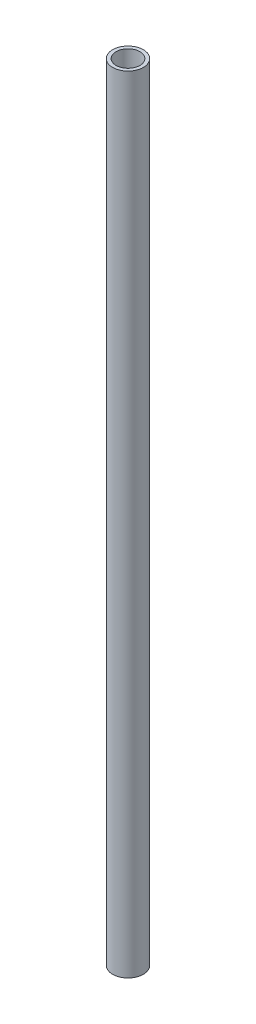
from build123d import *

# Parameters (mm, degrees)
SKETCH1_R           = 2.25
SKETCH1_R_2         = 1.75
BOSS_EXTRUDE1_DEPTH = 115


with BuildPart() as part:
    # Sketch1 → Boss-Extrude1 (new body)
    with BuildSketch(Plane(origin=(0, 0, 0), x_dir=(1, 0, 0), z_dir=(0, 1, 0))):
        Circle(SKETCH1_R)
        Circle(SKETCH1_R_2, mode=Mode.SUBTRACT)
    extrude(amount=BOSS_EXTRUDE1_DEPTH)


solid = part.part
